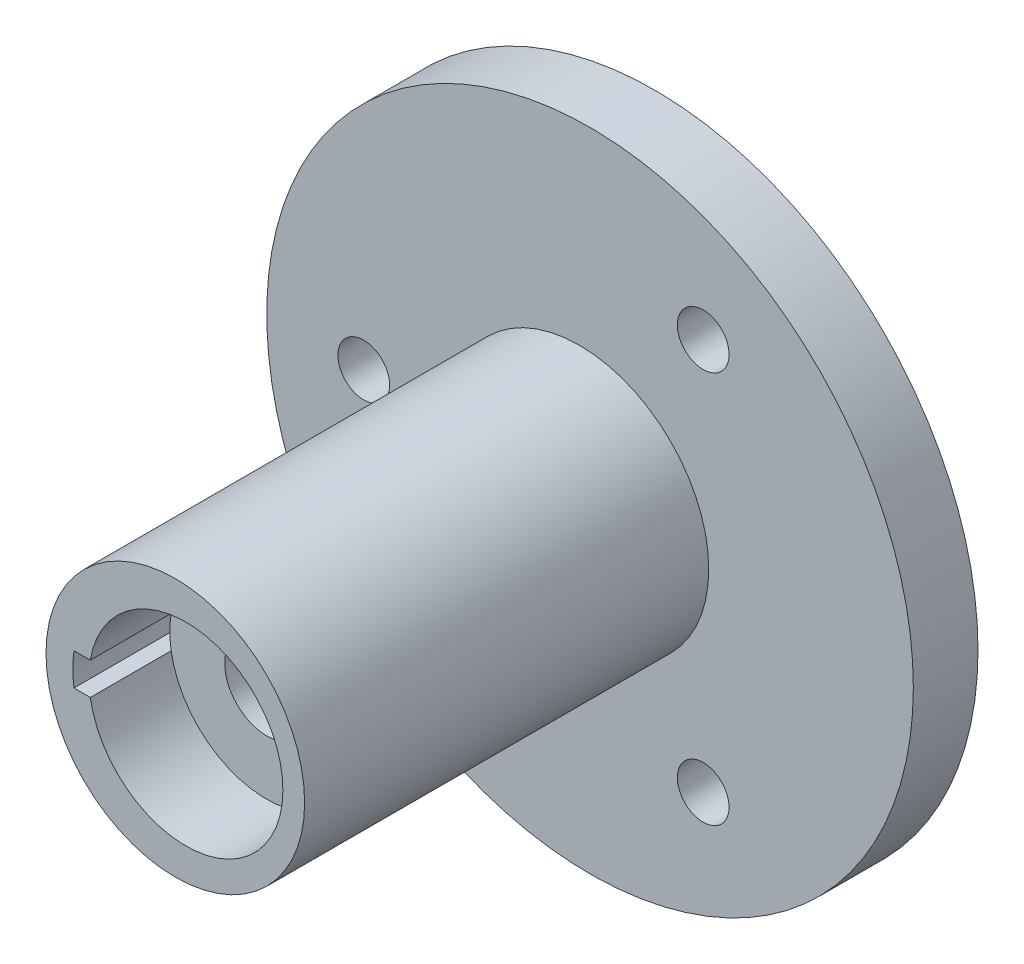
from build123d import *

# Parameters (mm, degrees)
SKETCH1_R               = 50
BOSS_EXTRUDE1_DEPTH     = 10
SKETCH1_3_R             = 4
CUT_EXTRUDE1_DEPTH      = 10
SKETCH1_4_R             = 20
BOSS_EXTRUDE2_DEPTH     = 62.5
SKETCH4_R               = 15
BOSS_EXTRUDE4_DEPTH     = 50
CUT_EXTRUDE3_DEPTH      = 95.372930441
CUT_EXTRUDE3_DEPTH_BACK = 95.372930441
SKETCH3_R               = 6.5


with BuildPart() as part:
    # Sketch1 → Boss-Extrude1 (new body)
    with BuildSketch(Plane.XY):
        Circle(SKETCH1_R)
    extrude(amount=-BOSS_EXTRUDE1_DEPTH)

    # Sketch1_3 → Cut-Extrude1 (cut)
    with BuildSketch(Plane.XY):
        with Locations((-35, 0)):
            Circle(SKETCH1_3_R)
        with Locations((17.5, 30.310889132)):
            Circle(SKETCH1_3_R)
        with Locations((17.5, -30.310889132)):
            Circle(SKETCH1_3_R)
    extrude(amount=-CUT_EXTRUDE1_DEPTH, mode=Mode.SUBTRACT)

    # Sketch1_4 → Boss-Extrude2 (add)
    with BuildSketch(Plane.XY):
        with Locations((-1.640921825, 0)):
            Circle(SKETCH1_4_R)
        with BuildLine():
            Line((-17.320508076, 2.5), (-14.790199458, 2.5))
            ThreePointArc((-14.790199458, 2.5), (15, 0), (-14.790199458, -2.5))
            Line((-14.790199458, -2.5), (-17.320508076, -2.5))
            ThreePointArc((-17.320508076, -2.5), (-17.5, 0), (-17.320508076, 2.5))
        make_face(mode=Mode.SUBTRACT)
    extrude(amount=BOSS_EXTRUDE2_DEPTH)

    # Sketch4 → Boss-Extrude4 (add)
    with BuildSketch(Plane.XY):
        Circle(SKETCH4_R)
    extrude(amount=BOSS_EXTRUDE4_DEPTH)

    # Sketch3 → Cut-Extrude3 (cut, two sides: drawn at the far end of the back side and taken through both)
    with BuildSketch(Plane.XY.offset(-CUT_EXTRUDE3_DEPTH_BACK)):
        Circle(SKETCH3_R)
    extrude(amount=CUT_EXTRUDE3_DEPTH + CUT_EXTRUDE3_DEPTH_BACK, mode=Mode.SUBTRACT)


solid = part.part
